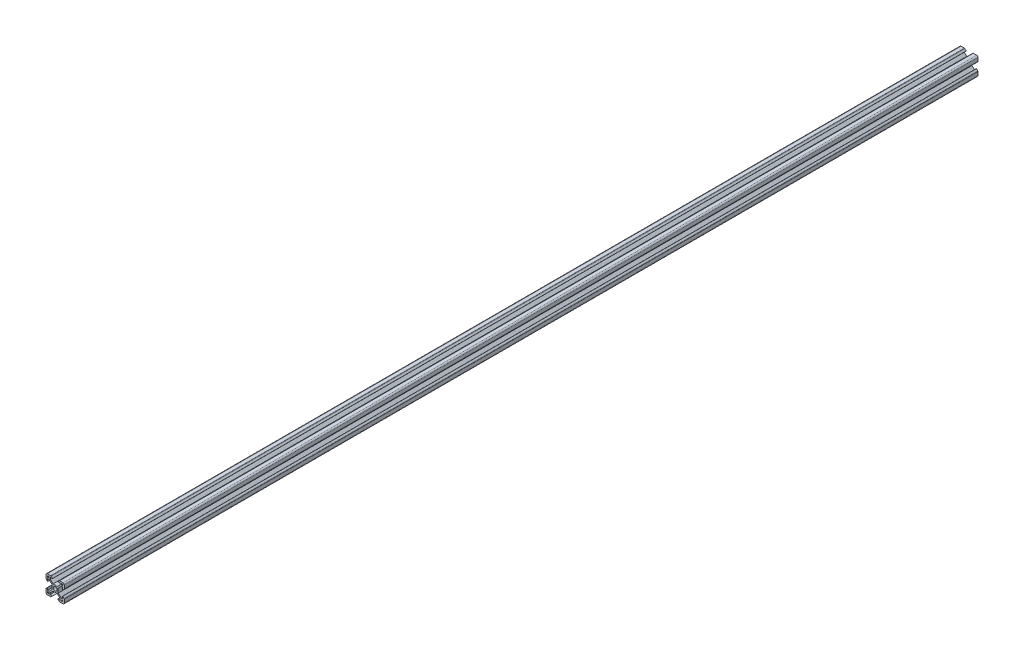
from build123d import *

# Parameters (mm, degrees)
SKETCH6_R           = 2.1
BOSS_EXTRUDE1_DEPTH = 1000


with BuildPart() as part:
    # Sketch6 → Boss-Extrude1 (new body)
    with BuildSketch(Plane.XY):
        with BuildLine():
            Line((-3.4, -2.339339828), (-3.4, 2.339339828))
            Line((-3.4, 2.339339828), (-6.560660172, 5.5))
            Line((-6.560660172, 5.5), (-8.2, 5.5))
            Line((-8.2, 5.5), (-8.2, 2.89))
            Line((-8.2, 2.89), (-8.31, 2.89))
            Line((-8.31, 2.89), (-9.768614357, 4.348614357))
            ThreePointArc((-9.768614357, 4.348614357), (-9.939864831, 4.604908803), (-10, 4.907228714))
            Line((-10, 4.907228714), (-10, 8.5))
            ThreePointArc((-10, 8.5), (-9.560660172, 9.560660172), (-8.5, 10))
            Line((-8.5, 10), (-4.907228714, 10))
            ThreePointArc((-4.907228714, 10), (-4.604908803, 9.939864831), (-4.348614357, 9.768614357))
            Line((-4.348614357, 9.768614357), (-2.89, 8.31))
            Line((-2.89, 8.31), (-2.89, 8.2))
            Line((-2.89, 8.2), (-5.5, 8.2))
            Line((-5.5, 8.2), (-5.5, 6.560660172))
            Line((-5.5, 6.560660172), (-2.339339828, 3.4))
            Line((-2.339339828, 3.4), (2.339339828, 3.4))
            Line((2.339339828, 3.4), (5.5, 6.560660172))
            Line((5.5, 6.560660172), (5.5, 8.2))
            Line((5.5, 8.2), (2.89, 8.2))
            Line((2.89, 8.2), (2.89, 8.31))
            Line((2.89, 8.31), (4.348614357, 9.768614357))
            ThreePointArc((4.348614357, 9.768614357), (4.604908803, 9.939864831), (4.907228714, 10))
            Line((4.907228714, 10), (8.5, 10))
            ThreePointArc((8.5, 10), (9.560660172, 9.560660172), (10, 8.5))
            Line((10, 8.5), (10, 4.907228714))
            ThreePointArc((10, 4.907228714), (9.939864831, 4.604908803), (9.768614357, 4.348614357))
            Line((9.768614357, 4.348614357), (8.31, 2.89))
            Line((8.31, 2.89), (8.2, 2.89))
            Line((8.2, 2.89), (8.2, 5.5))
            Line((8.2, 5.5), (6.560660172, 5.5))
            Line((6.560660172, 5.5), (3.4, 2.339339828))
            Line((3.4, 2.339339828), (3.4, -2.339339828))
            Line((3.4, -2.339339828), (6.560660172, -5.5))
            Line((6.560660172, -5.5), (8.2, -5.5))
            Line((8.2, -5.5), (8.2, -2.89))
            Line((8.2, -2.89), (8.31, -2.89))
            Line((8.31, -2.89), (9.768614357, -4.348614357))
            ThreePointArc((9.768614357, -4.348614357), (9.939864831, -4.604908803), (10, -4.907228714))
            Line((10, -4.907228714), (10, -8.5))
            ThreePointArc((10, -8.5), (9.560660172, -9.560660172), (8.5, -10))
            Line((8.5, -10), (4.907228714, -10))
            ThreePointArc((4.907228714, -10), (4.604908803, -9.939864831), (4.348614357, -9.768614357))
            Line((4.348614357, -9.768614357), (2.89, -8.31))
            Line((2.89, -8.31), (2.89, -8.2))
            Line((2.89, -8.2), (5.5, -8.2))
            Line((5.5, -8.2), (5.5, -6.560660172))
            Line((5.5, -6.560660172), (2.339339828, -3.4))
            Line((2.339339828, -3.4), (-2.339339828, -3.4))
            Line((-2.339339828, -3.4), (-5.5, -6.560660172))
            Line((-5.5, -6.560660172), (-5.5, -8.2))
            Line((-5.5, -8.2), (-2.89, -8.2))
            Line((-2.89, -8.2), (-2.89, -8.31))
            Line((-2.89, -8.31), (-4.348614357, -9.768614357))
            ThreePointArc((-4.348614357, -9.768614357), (-4.604908803, -9.939864831), (-4.907228714, -10))
            Line((-4.907228714, -10), (-8.5, -10))
            ThreePointArc((-8.5, -10), (-9.560660172, -9.560660172), (-10, -8.5))
            Line((-10, -8.5), (-10, -4.907228714))
            ThreePointArc((-10, -4.907228714), (-9.939864831, -4.604908803), (-9.768614357, -4.348614357))
            Line((-9.768614357, -4.348614357), (-8.31, -2.89))
            Line((-8.31, -2.89), (-8.2, -2.89))
            Line((-8.2, -2.89), (-8.2, -5.5))
            Line((-8.2, -5.5), (-6.560660172, -5.5))
            Line((-6.560660172, -5.5), (-3.4, -2.339339828))
        make_face()
        Circle(SKETCH6_R, mode=Mode.SUBTRACT)
        Polygon((-7.66, 6.57), (-6.57, 7.66), (-6.57, 8.2), (-8.2, 8.2), (-8.2, 6.57), align=None, mode=Mode.SUBTRACT)
        Polygon((8.2, 6.57), (7.66, 6.57), (6.57, 7.66), (6.57, 8.2), (8.2, 8.2), align=None, mode=Mode.SUBTRACT)
        Polygon((7.66, -6.57), (6.57, -7.66), (6.57, -8.2), (8.2, -8.2), (8.2, -6.57), align=None, mode=Mode.SUBTRACT)
        Polygon((-8.2, -6.57), (-7.66, -6.57), (-6.57, -7.66), (-6.57, -8.2), (-8.2, -8.2), align=None, mode=Mode.SUBTRACT)
    extrude(amount=-BOSS_EXTRUDE1_DEPTH)


solid = part.part
